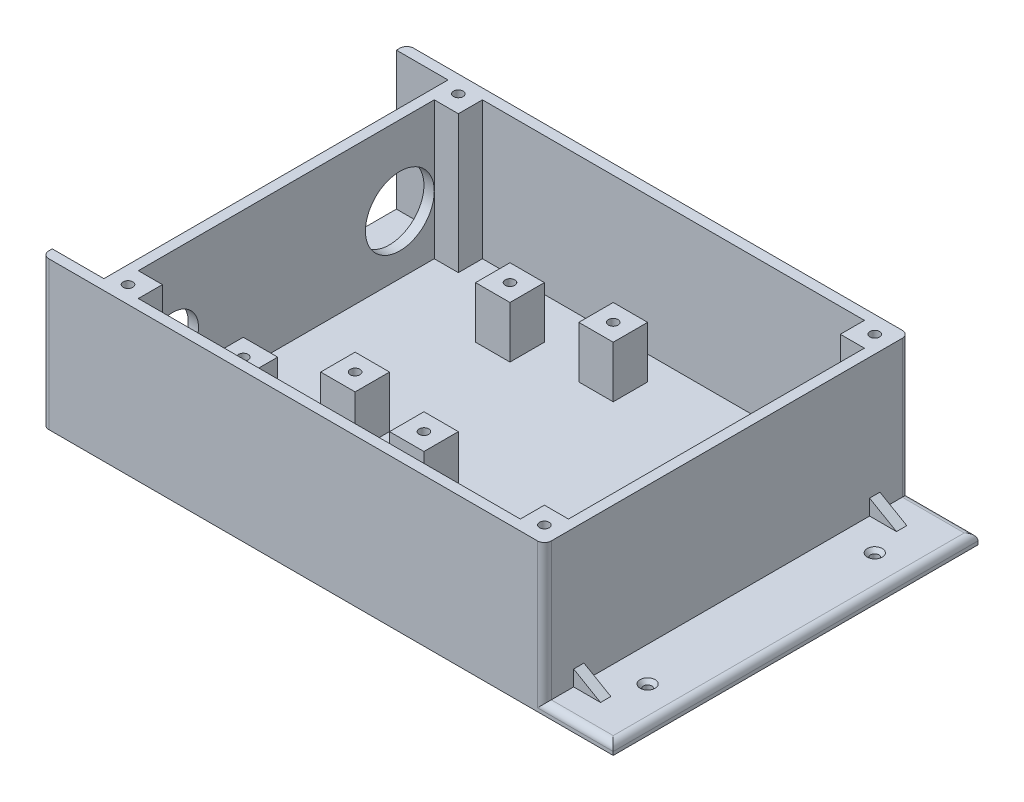
from build123d import *

# Parameters (mm, degrees)
SKETCH1_W                                      = 166
SKETCH1_H                                      = 106
BOSS_EXTRUDE1_DEPTH                            = 43
SHELL1_T                                       = -3
SKETCH2_W                                      = 3
SKETCH2_H                                      = 100
BOSS_EXTRUDE2_DEPTH                            = 40
SKETCH3_R                                      = 10
CUT_EXTRUDE1_DEPTH                             = 3
SKETCH4_R                                      = 7.5
CUT_EXTRUDE3_DEPTH                             = 3
SKETCH5_W                                      = 3
SKETCH5_H                                      = 100
BOSS_EXTRUDE4_DEPTH                            = 40
SKETCH6_W                                      = 3
SKETCH6_H                                      = 40
CUT_EXTRUDE4_DEPTH                             = 20
CSK_FOR_2_FLAT_HEAD_MACHINE_SCREW1_D           = 2.4384
CSK_FOR_2_FLAT_HEAD_MACHINE_SCREW1_CSINK_D     = 4.3688
CSK_FOR_2_FLAT_HEAD_MACHINE_SCREW1_CSINK_ANGLE = 82
CSK_FOR_2_FLAT_HEAD_MACHINE_SCREW2_D           = 2.4384
CSK_FOR_2_FLAT_HEAD_MACHINE_SCREW2_CSINK_D     = 4.3688
CSK_FOR_2_FLAT_HEAD_MACHINE_SCREW2_CSINK_ANGLE = 82
BOSS_EXTRUDE6_DEPTH                            = 1.5
SKETCH17_W                                     = 7
SKETCH17_H                                     = 7
BOSS_EXTRUDE7_DEPTH                            = 40
SKETCH20_W                                     = 10
SKETCH20_H                                     = 10
BOSS_EXTRUDE8_DEPTH                            = 15
SKETCH21_W                                     = 10
SKETCH21_H                                     = 10
BOSS_EXTRUDE9_DEPTH                            = 15
SKETCH22_W                                     = 10
SKETCH22_H                                     = 10
BOSS_EXTRUDE10_DEPTH                           = 15
SKETCH23_W                                     = 10
SKETCH23_H                                     = 10
BOSS_EXTRUDE11_DEPTH                           = 15
SKETCH24_W                                     = 10
SKETCH24_H                                     = 10
BOSS_EXTRUDE12_DEPTH                           = 15
SKETCH25_W                                     = 10
SKETCH25_H                                     = 10
BOSS_EXTRUDE13_DEPTH                           = 15
SKETCH26_W                                     = 10
SKETCH26_H                                     = 10
BOSS_EXTRUDE14_DEPTH                           = 15
SKETCH27_W                                     = 10
SKETCH27_H                                     = 10
BOSS_EXTRUDE15_DEPTH                           = 15
SKETCH28_R                                     = 1.4
CUT_EXTRUDE5_DEPTH                             = 10
MIRROR4_COPY_1_SKETCH_W                        = 7
MIRROR4_COPY_1_SKETCH_H                        = 7
MIRROR4_COPY_1_DEPTH                           = 40
MIRROR4_COPY_2_SKETCH_R                        = 1.4
MIRROR4_COPY_2_DEPTH                           = 10
FILLET2_R                                      = 2
FILLET3_R                                      = 2
SKETCH29_R                                     = 1.4
CUT_EXTRUDE6_DEPTH                             = 10
MIRROR6_COPY_1_SKETCH_R                        = 1.4
MIRROR6_COPY_1_DEPTH                           = 10
SKETCH30_R                                     = 1.4
CUT_EXTRUDE7_DEPTH                             = 10
SKETCH31_R                                     = 1.4
CUT_EXTRUDE8_DEPTH                             = 10
SKETCH32_R                                     = 1.4
CUT_EXTRUDE9_DEPTH                             = 10


with BuildPart() as part:
    # Sketch1 → Boss-Extrude1 (new body)
    with BuildSketch(Plane(origin=(0, 0, 0), x_dir=(1, 0, 0), z_dir=(0, 1, 0))):
        with Locations((83, 53)):
            Rectangle(SKETCH1_W, SKETCH1_H)
    extrude(amount=BOSS_EXTRUDE1_DEPTH)

    # Shell1
    shell1_openings = [part.faces().sort_by_distance(p)[0] for p in [
        (83, 43, -53),
        (166, 21.5, -53),
        (0, 21.5, -53),
    ]]
    offset(amount=SHELL1_T, openings=shell1_openings, kind=Kind.INTERSECTION)

    # Sketch2 → Boss-Extrude2 (add)
    with BuildSketch(Plane(origin=(0, 3, 0), x_dir=(1, 0, 0), z_dir=(0, 1, 0))):
        with Locations((16.5, 53)):
            Rectangle(SKETCH2_W, SKETCH2_H)
    extrude(amount=BOSS_EXTRUDE2_DEPTH)

    # Sketch3 → Cut-Extrude1 (cut)
    with BuildSketch(Plane.ZY.offset(-15)):
        with Locations((-86, 20)):
            Circle(SKETCH3_R)
    extrude(amount=-CUT_EXTRUDE1_DEPTH, mode=Mode.SUBTRACT)

    # Sketch4 → Cut-Extrude3 (cut)
    with BuildSketch(Plane.ZY.offset(-15)):
        with Locations((-20, 20)):
            Circle(SKETCH4_R)
    extrude(amount=-CUT_EXTRUDE3_DEPTH, mode=Mode.SUBTRACT)

    # Sketch5 → Boss-Extrude4 (add)
    with BuildSketch(Plane(origin=(0, 3, 0), x_dir=(1, 0, 0), z_dir=(0, 1, 0))):
        with Locations((144.5, 53)):
            Rectangle(SKETCH5_W, SKETCH5_H)
    extrude(amount=BOSS_EXTRUDE4_DEPTH)

    # Sketch6 → Cut-Extrude4 (cut)
    with BuildSketch(Plane(origin=(166, 0, 0), x_dir=(0, 0, -1), z_dir=(1, 0, 0))):
        with Locations((104.5, 23)):
            Rectangle(SKETCH6_W, SKETCH6_H)
    cut_extrude4 = extrude(amount=-CUT_EXTRUDE4_DEPTH, mode=Mode.SUBTRACT)

    # Mirror1: Cut-Extrude4 across plane
    add(cut_extrude4.mirror(Plane(origin=(0, 0, -53), x_dir=(1, 0, 0), z_dir=(0, 0, -1))), mode=Mode.SUBTRACT)

    # CSK for #2 Flat Head Machine Screw1 (through all)
    with Locations(Plane(origin=(156, 3, -86), x_dir=(0, 0, 1), z_dir=(0, 1, 0))):
        with Locations((0, 0), (66, 0)):
            CounterSinkHole(CSK_FOR_2_FLAT_HEAD_MACHINE_SCREW1_D / 2, CSK_FOR_2_FLAT_HEAD_MACHINE_SCREW1_CSINK_D / 2, counter_sink_angle=CSK_FOR_2_FLAT_HEAD_MACHINE_SCREW1_CSINK_ANGLE)

    # CSK for #2 Flat Head Machine Screw2 (through all)
    with Locations(Plane(origin=(0, 3, 0), x_dir=(1, 0, 0), z_dir=(0, 1, 0))):
        with Locations((7.5, 20), (7.5, 86)):
            CounterSinkHole(CSK_FOR_2_FLAT_HEAD_MACHINE_SCREW2_D / 2, CSK_FOR_2_FLAT_HEAD_MACHINE_SCREW2_CSINK_D / 2, counter_sink_angle=CSK_FOR_2_FLAT_HEAD_MACHINE_SCREW2_CSINK_ANGLE)

    # Sketch16 → Boss-Extrude6 (add, symmetric)
    with BuildSketch(Plane(origin=(0, 0, -96), x_dir=(-1, 0, 0), z_dir=(0, 0, -1))):
        Polygon((-153.8156, 3), (-146, 7.512338764), (-146, 3), align=None)
    boss_extrude6 = extrude(amount=BOSS_EXTRUDE6_DEPTH, both=True)

    # Mirror2: Boss-Extrude6 across plane
    add(boss_extrude6.mirror(Plane(origin=(0, 0, -53), x_dir=(1, 0, 0), z_dir=(0, 0, -1))))

    # Sketch17 → Boss-Extrude7 (add)
    with BuildSketch(Plane(origin=(0, 3, 0), x_dir=(1, 0, 0), z_dir=(0, 1, 0))):
        with Locations((139.5, 99.5)):
            Rectangle(SKETCH17_W, SKETCH17_H)
    boss_extrude7 = extrude(amount=BOSS_EXTRUDE7_DEPTH)

    # Sketch20 → Boss-Extrude8 (add)
    with BuildSketch(Plane(origin=(0, 3, 0), x_dir=(1, 0, 0), z_dir=(0, 1, 0))):
        with Locations((138, 91)):
            Rectangle(SKETCH20_W, SKETCH20_H)
    extrude(amount=BOSS_EXTRUDE8_DEPTH)

    # Sketch21 → Boss-Extrude9 (add)
    with BuildSketch(Plane(origin=(0, 3, 0), x_dir=(1, 0, 0), z_dir=(0, 1, 0))):
        with Locations((30, 28.5)):
            Rectangle(SKETCH21_W, SKETCH21_H)
    extrude(amount=BOSS_EXTRUDE9_DEPTH)

    # Sketch22 → Boss-Extrude10 (add)
    with BuildSketch(Plane(origin=(0, 3, 0), x_dir=(1, 0, 0), z_dir=(0, 1, 0))):
        with Locations((64, 12.5)):
            Rectangle(SKETCH22_W, SKETCH22_H)
    extrude(amount=BOSS_EXTRUDE10_DEPTH)

    # Sketch23 → Boss-Extrude11 (add)
    with BuildSketch(Plane(origin=(0, 3, 0), x_dir=(1, 0, 0), z_dir=(0, 1, 0))):
        with Locations((50, 86)):
            Rectangle(SKETCH23_W, SKETCH23_H)
    extrude(amount=BOSS_EXTRUDE11_DEPTH)

    # Sketch24 → Boss-Extrude12 (add)
    with BuildSketch(Plane(origin=(0, 3, 0), x_dir=(1, 0, 0), z_dir=(0, 1, 0))):
        with Locations((50, 41)):
            Rectangle(SKETCH24_W, SKETCH24_H)
    extrude(amount=BOSS_EXTRUDE12_DEPTH)

    # Sketch25 → Boss-Extrude13 (add)
    with BuildSketch(Plane(origin=(0, 3, 0), x_dir=(1, 0, 0), z_dir=(0, 1, 0))):
        with Locations((138, 36)):
            Rectangle(SKETCH25_W, SKETCH25_H)
    extrude(amount=BOSS_EXTRUDE13_DEPTH)

    # Sketch26 → Boss-Extrude14 (add)
    with BuildSketch(Plane(origin=(0, 3, 0), x_dir=(1, 0, 0), z_dir=(0, 1, 0))):
        with Locations((75, 91)):
            Rectangle(SKETCH26_W, SKETCH26_H)
    extrude(amount=BOSS_EXTRUDE14_DEPTH)

    # Sketch27 → Boss-Extrude15 (add)
    with BuildSketch(Plane(origin=(0, 3, 0), x_dir=(1, 0, 0), z_dir=(0, 1, 0))):
        with Locations((75, 36)):
            Rectangle(SKETCH27_W, SKETCH27_H)
    extrude(amount=BOSS_EXTRUDE15_DEPTH)

    # Sketch28 → Cut-Extrude5 (cut)
    with BuildSketch(Plane(origin=(0, 43, 0), x_dir=(1, 0, 0), z_dir=(0, 1, 0))):
        with Locations((141, 101)):
            Circle(SKETCH28_R)
    cut_extrude5 = extrude(amount=-CUT_EXTRUDE5_DEPTH, mode=Mode.SUBTRACT)

    # Mirror3: Boss-Extrude7, Cut-Extrude5 across plane
    add(boss_extrude7.mirror(Plane(origin=(0, 0, -53), x_dir=(1, 0, 0), z_dir=(0, 0, -1))))
    add(cut_extrude5.mirror(Plane(origin=(0, 0, -53), x_dir=(1, 0, 0), z_dir=(0, 0, -1))), mode=Mode.SUBTRACT)

    # Mirror4: Boss-Extrude7, Cut-Extrude5 across plane
    add(boss_extrude7.mirror(Plane.ZY.offset(-80.5)))
    add(cut_extrude5.mirror(Plane.ZY.offset(-80.5)), mode=Mode.SUBTRACT)

    # Mirror4 copy 1 sketch → Mirror4 copy 1 (add)
    with BuildSketch(Plane(origin=(161, 3, -106), x_dir=(-1, 0, 0), z_dir=(0, 1, 0))):
        with Locations((139.5, 99.5)):
            Rectangle(MIRROR4_COPY_1_SKETCH_W, MIRROR4_COPY_1_SKETCH_H)
    extrude(amount=MIRROR4_COPY_1_DEPTH)

    # Mirror4 copy 2 sketch → Mirror4 copy 2 (cut)
    with BuildSketch(Plane(origin=(161, 43, -106), x_dir=(-1, 0, 0), z_dir=(0, 1, 0))):
        with Locations((141, 101)):
            Circle(MIRROR4_COPY_2_SKETCH_R)
    extrude(amount=-MIRROR4_COPY_2_DEPTH, mode=Mode.SUBTRACT)

    # Fillet2
    fillet2_edges = [part.edges().sort_by_distance(p)[0] for p in [
        (146, 23, -106),
        (0, 21.5, -106),
        (0, 21.5, 0),
        (146, 23, 0),
    ]]
    fillet(fillet2_edges, radius=FILLET2_R)

    # Fillet3
    fillet3_edges = [part.edges().sort_by_distance(p)[0] for p in [
        (156, 3, 0),
        (156, 3, -106),
        (166, 3, -53),
    ]]
    fillet(fillet3_edges, radius=FILLET3_R)

    # Sketch29 → Cut-Extrude6 (cut)
    with BuildSketch(Plane(origin=(0, 18, 0), x_dir=(1, 0, 0), z_dir=(0, 1, 0))):
        with Locations((138, 91)):
            Circle(SKETCH29_R)
    cut_extrude6 = extrude(amount=-CUT_EXTRUDE6_DEPTH, mode=Mode.SUBTRACT)

    # Mirror5: Cut-Extrude6 across plane
    add(cut_extrude6.mirror(Plane(origin=(0, 0, -63.5), x_dir=(1, 0, 0), z_dir=(0, 0, -1))), mode=Mode.SUBTRACT)

    # Mirror6: Cut-Extrude6 across plane
    add(cut_extrude6.mirror(Plane.ZY.offset(-106.5)), mode=Mode.SUBTRACT)

    # Mirror6 copy 1 sketch → Mirror6 copy 1 (cut)
    with BuildSketch(Plane(origin=(213, 18, -127), x_dir=(-1, 0, 0), z_dir=(0, 1, 0))):
        with Locations((138, 91)):
            Circle(MIRROR6_COPY_1_SKETCH_R)
    extrude(amount=-MIRROR6_COPY_1_DEPTH, mode=Mode.SUBTRACT)

    # Sketch30 → Cut-Extrude7 (cut)
    with BuildSketch(Plane(origin=(0, 18, 0), x_dir=(1, 0, 0), z_dir=(0, 1, 0))):
        with Locations((50, 86)):
            Circle(SKETCH30_R)
    cut_extrude7 = extrude(amount=-CUT_EXTRUDE7_DEPTH, mode=Mode.SUBTRACT)

    # Mirror7: Cut-Extrude7 across plane
    add(cut_extrude7.mirror(Plane.XY.offset(-63.5)), mode=Mode.SUBTRACT)

    # Sketch31 → Cut-Extrude8 (cut)
    with BuildSketch(Plane(origin=(0, 18, 0), x_dir=(1, 0, 0), z_dir=(0, 1, 0))):
        with Locations((64, 12.5)):
            Circle(SKETCH31_R)
    extrude(amount=-CUT_EXTRUDE8_DEPTH, mode=Mode.SUBTRACT)

    # Sketch32 → Cut-Extrude9 (cut)
    with BuildSketch(Plane(origin=(0, 18, 0), x_dir=(1, 0, 0), z_dir=(0, 1, 0))):
        with Locations((30, 28.5)):
            Circle(SKETCH32_R)
    extrude(amount=-CUT_EXTRUDE9_DEPTH, mode=Mode.SUBTRACT)


solid = part.part
